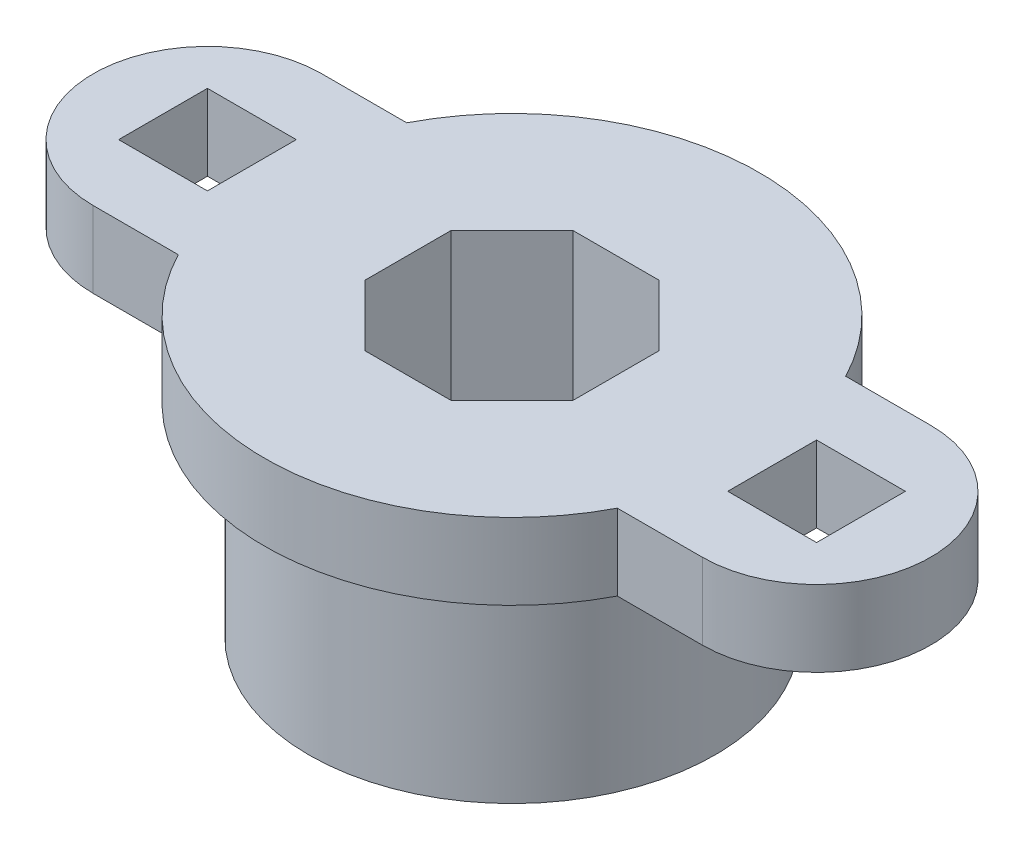
from build123d import *

# Parameters (mm, degrees)
SKETCH1_R           = 8
BOSS_EXTRUDE1_DEPTH = 8
SKETCH2_R           = 9.75
BOSS_EXTRUDE2_DEPTH = 3
BOSS_EXTRUDE3_DEPTH = 3
CUT_EXTRUDE2_REACH  = 13
SKETCH5_W           = 3.5
SKETCH5_H           = 3.5
CUT_EXTRUDE1_DEPTH  = 12


with BuildPart() as part:
    # Sketch1 → Boss-Extrude1 (new body)
    with BuildSketch(Plane(origin=(0, 0, 0), x_dir=(1, 0, 0), z_dir=(0, 1, 0))):
        Circle(SKETCH1_R)
    extrude(amount=BOSS_EXTRUDE1_DEPTH)

    # Sketch2 → Boss-Extrude2 (add)
    with BuildSketch(Plane(origin=(0, 8, 0), x_dir=(1, 0, 0), z_dir=(0, 1, 0))):
        Circle(SKETCH2_R)
    extrude(amount=BOSS_EXTRUDE2_DEPTH)

    # Sketch4 → Boss-Extrude3 (add)
    with BuildSketch(Plane(origin=(0, 11, 0), x_dir=(1, 0, 0), z_dir=(0, 1, 0))):
        with BuildLine():
            Line((12, -4.5), (-12, -4.5))
            ThreePointArc((-12, -4.5), (-16.5, 0), (-12, 4.5))
            Line((-12, 4.5), (12, 4.5))
            ThreePointArc((12, 4.5), (16.5, 0), (12, -4.5))
        make_face()
    extrude(amount=-BOSS_EXTRUDE3_DEPTH)

    # Sketch5 → Cut-Extrude2 (cut, up to next)
    with BuildSketch(Plane(origin=(0, 11, 0), x_dir=(1, 0, 0), z_dir=(0, 1, 0)), mode=Mode.PRIVATE) as cut_extrude2_sk1:
        with Locations((-12, 0)):
            Rectangle(SKETCH5_W, SKETCH5_H)
    cut_extrude2_tool1 = extrude(cut_extrude2_sk1.sketch, amount=-CUT_EXTRUDE2_REACH, mode=Mode.PRIVATE) & part.part
    add(cut_extrude2_tool1.solids().sort_by_distance((-12, 11, 0))[0], mode=Mode.SUBTRACT)
    # Sketch5 → Cut-Extrude2 (cut, up to next)
    with BuildSketch(Plane(origin=(0, 11, 0), x_dir=(1, 0, 0), z_dir=(0, 1, 0)), mode=Mode.PRIVATE) as cut_extrude2_sk2:
        with Locations((12, 0)):
            Rectangle(SKETCH5_W, SKETCH5_H)
    cut_extrude2_tool2 = extrude(cut_extrude2_sk2.sketch, amount=-CUT_EXTRUDE2_REACH, mode=Mode.PRIVATE) & part.part
    add(cut_extrude2_tool2.solids().sort_by_distance((12, 11, 0))[0], mode=Mode.SUBTRACT)

    # Sketch3 → Cut-Extrude1 (cut, through all)
    with BuildSketch(Plane(origin=(0, 11, 0), x_dir=(1, 0, 0), z_dir=(0, 1, 0))):
        Polygon((4.1, 1.698275606), (1.698275606, 4.1), (-1.698275606, 4.1), (-4.1, 1.698275606), (-4.1, -1.698275606), (-1.698275606, -4.1), (1.698275606, -4.1), (4.1, -1.698275606), align=None)
    extrude(amount=-CUT_EXTRUDE1_DEPTH, mode=Mode.SUBTRACT)


solid = part.part
